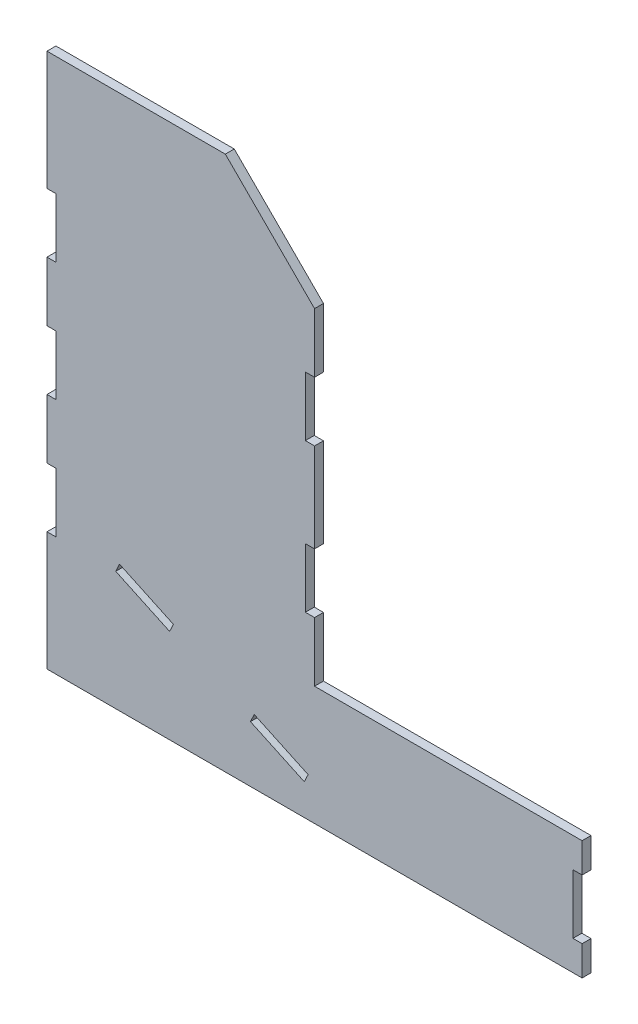
from build123d import *

# Parameters (mm, degrees)
BOSS_EXTRUDE1_DEPTH          = 1.5
CUT_EXTRUDE_THIN1_DEPTH      = 149.017202979
CUT_EXTRUDE_THIN1_DEPTH_BACK = 149.017202979
SKETCH1_3_W                  = 3.18
SKETCH1_3_H                  = 20
CUT_EXTRUDE1_REACH           = 150.04


with BuildPart() as part:
    # Sketch1 → Boss-Extrude1 (new, symmetric)
    with BuildSketch(Plane.XY):
        Polygon((-33.914893617, 114.397705985), (-93.914893617, 114.397705985), (-93.914893617, -65.602294015), (86.085106383, -65.602294015), (86.085106383, -25.602294015), (-3.914893617, -25.602294015), (-3.914893617, 84.397705985), align=None)
    extrude(amount=BOSS_EXTRUDE1_DEPTH, both=True)

    # Sketch1_3 → Cut-Extrude-Thin1 (cut, two sides: drawn at the far end of the back side and taken through both)
    with BuildSketch(Plane.XY.offset(-CUT_EXTRUDE_THIN1_DEPTH_BACK)):
        with Locations((-92.414893617, 64.397705985)):
            Rectangle(SKETCH1_3_W, SKETCH1_3_H)
        with Locations((-92.414893617, 24.397705985)):
            Rectangle(SKETCH1_3_W, SKETCH1_3_H)
        with Locations((-92.414893617, -15.602294015)):
            Rectangle(SKETCH1_3_W, SKETCH1_3_H)
        with Locations((-5.414893617, 54.397705985)):
            Rectangle(SKETCH1_3_W, SKETCH1_3_H)
        with Locations((-5.414893617, 4.397705985)):
            Rectangle(SKETCH1_3_W, SKETCH1_3_H)
        with Locations((84.585106383, -45.602294015)):
            Rectangle(SKETCH1_3_W, SKETCH1_3_H)
    extrude(amount=CUT_EXTRUDE_THIN1_DEPTH + CUT_EXTRUDE_THIN1_DEPTH_BACK, mode=Mode.SUBTRACT)

    # Sketch2 → Cut-Extrude1 (cut, up to next)
    with BuildSketch(Plane.XY.offset(1.5), mode=Mode.PRIVATE) as cut_extrude1_sk1:
        Polygon((-25.473348524, -46.697563546), (-7.347192784, -55.14992878), (-6.079337999, -52.431005419), (-24.205493739, -43.978640185), align=None)
    cut_extrude1_tool1 = extrude(cut_extrude1_sk1.sketch, amount=-CUT_EXTRUDE1_REACH, mode=Mode.PRIVATE) & part.part
    # Sketch2 → Cut-Extrude1 (cut, up to next)
    with BuildSketch(Plane.XY.offset(1.5), mode=Mode.PRIVATE) as cut_extrude1_sk2:
        Polygon((-51.39472735, -31.300092332), (-69.520883091, -22.847727097), (-70.788737876, -25.566650459), (-52.662582136, -34.019015693), align=None)
    cut_extrude1_tool2 = extrude(cut_extrude1_sk2.sketch, amount=-CUT_EXTRUDE1_REACH, mode=Mode.PRIVATE) & part.part
    add(cut_extrude1_tool1.solids().sort_by_distance((-15.776343, -49.564284, 1.5))[0], mode=Mode.SUBTRACT)
    add(cut_extrude1_tool2.solids().sort_by_distance((-61.091733, -28.433371, 1.5))[0], mode=Mode.SUBTRACT)


solid = part.part
